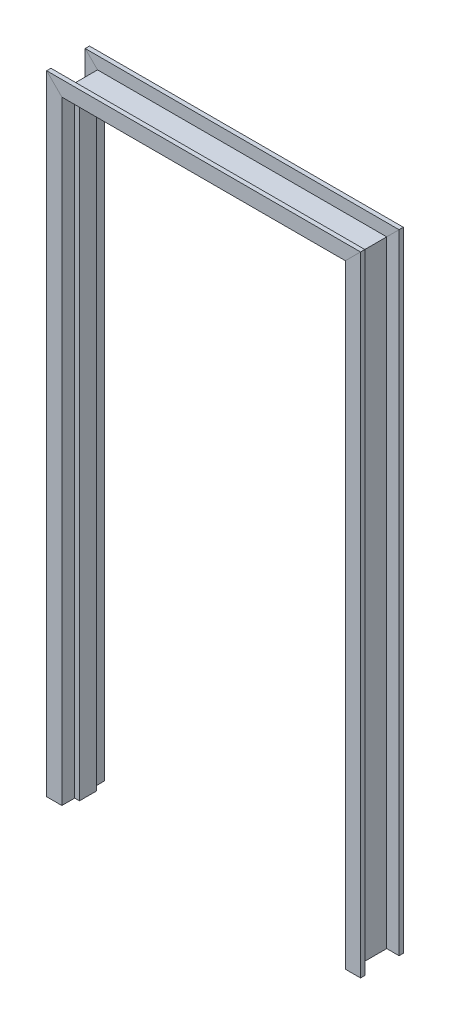
from build123d import *


with BuildPart() as part:
    # Sweep1: sweep along a path in Sketch1
    with BuildLine(Plane.XY) as sweep1_path:
        Line((0, 0), (0, 2032))
        Line((0, 2032), (914.4, 2032))
        Line((914.4, 2032), (914.4, 0))
    # Sketch2 → Sweep1 (sweep)
    with BuildSketch(Plane(origin=(0, 0, 0), x_dir=(1, 0, 0), z_dir=(0, 1, 0))):
        Polygon((0, 0), (0, 57.15), (-15.875, 57.15), (-15.875, 100.0125), (-66.675, 100.0125), (-66.675, 85.725), (-25.4, 85.725), (-25.4, -28.575), (-66.675, -28.575), (-66.675, -42.8625), (-15.875, -42.8625), (-15.875, 0), align=None)
    sweep(path=sweep1_path.line, transition=Transition.RIGHT)


solid = part.part
